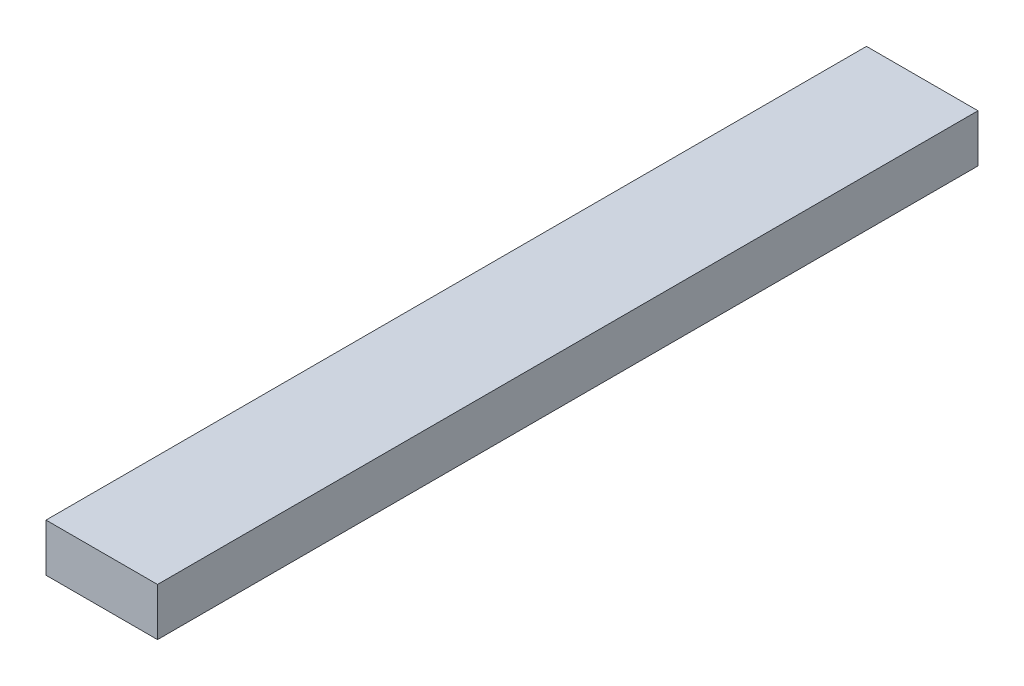
from build123d import *

# Parameters (mm, degrees)
SKETCH1_W           = 88.9
SKETCH1_H           = 38.1
BOSS_EXTRUDE1_DEPTH = 654.05


with BuildPart() as part:
    # Sketch1 → Boss-Extrude1 (new body)
    with BuildSketch(Plane.XY):
        with Locations((-28.718223127, 55.64884493)):
            Rectangle(SKETCH1_W, SKETCH1_H)
    extrude(amount=BOSS_EXTRUDE1_DEPTH)


solid = part.part
